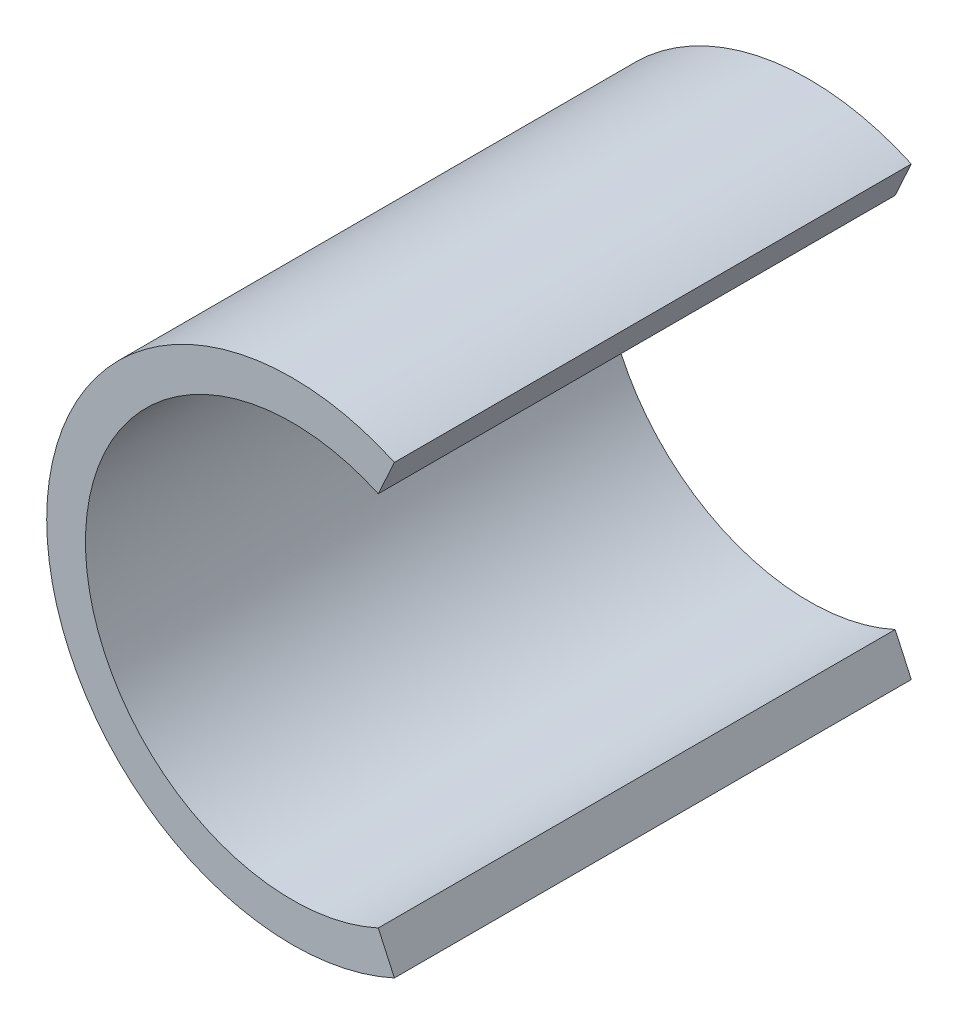
from build123d import *

# Parameters (mm, degrees)
SKETCH1_R           = 4.75
SKETCH1_R_2         = 4
BOSS_EXTRUDE1_DEPTH = 10
CUT_EXTRUDE2_DEPTH  = 10
SKETCH4_W           = 8.174166442
SKETCH4_H           = 1.582309943
BOSS_EXTRUDE2_DEPTH = 0.5


with BuildPart() as part:
    # Sketch1 → Boss-Extrude1 (new body)
    with BuildSketch(Plane.XY):
        Circle(SKETCH1_R)
        Circle(SKETCH1_R_2, mode=Mode.SUBTRACT)
    extrude(amount=BOSS_EXTRUDE1_DEPTH)

    # Sketch3 → Cut-Extrude2 (cut)
    with BuildSketch(Plane.XY.offset(10)):
        with BuildLine():
            ThreePointArc((1.66450103, 3.637229209), (3.365858295, 2.161249162), (4, 0))
            Line((4, 0), (4.75, 0))
            ThreePointArc((4.75, 0), (4.749994219, 0.007410728), (4.749976876, 0.014821438))
            ThreePointArc((4.749976876, 0.014821438), (3.992947753, 2.572716122), (1.976594973, 4.319209686))
            Line((1.976594973, 4.319209686), (1.66450103, 3.637229209))
        make_face()
        with BuildLine():
            Line((4.75, 0), (4, 0))
            ThreePointArc((4, 0), (3.365858295, -2.161249162), (1.66450103, -3.637229209))
            Line((1.66450103, -3.637229209), (1.976594973, -4.319209686))
            ThreePointArc((1.976594973, -4.319209686), (3.996956725, -2.56648338), (4.75, 0))
        make_face()
    extrude(amount=-CUT_EXTRUDE2_DEPTH, mode=Mode.SUBTRACT)

    # Sketch4 → Boss-Extrude2 (add)
    with BuildSketch(Plane(origin=(-4.5, 0, 0), x_dir=(0, 0, -1), z_dir=(1, 0, 0))):
        with Locations((-5.116351143, 0.000178202)):
            Rectangle(SKETCH4_W, SKETCH4_H)
    extrude(amount=-BOSS_EXTRUDE2_DEPTH)


solid = part.part
